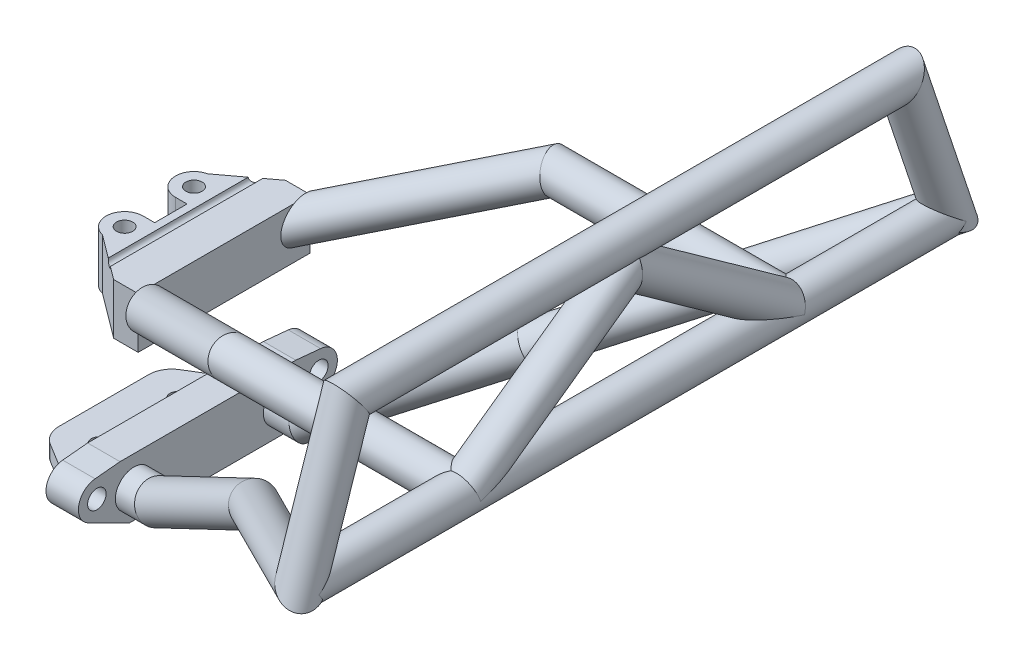
from build123d import *

# Parameters (mm, degrees)
SKETCH1_R               = 1.7
BOSS_EXTRUDE1_DEPTH     = 12.5
SKETCH2_W               = 15.5
SKETCH2_H               = 9.3
CUT_EXTRUDE1_DEPTH      = 55.465585465
BOSS_EXTRUDE2_DEPTH     = 7
CUT_EXTRUDE2_START      = -7
CUT_EXTRUDE2_DEPTH      = 15.157895
CUT_EXTRUDE3_REACH      = 36.358
SKETCH6_R               = 2
BOSS_EXTRUDE3_DEPTH     = 15
CUT_EXTRUDE4_REACH      = 39.104
SKETCH8_W               = 4.5
SKETCH8_H               = 10
SWEEP1_PROFILE_R        = 4
SWEEP4_PROFILE_R        = 4
SWEEP5_PROFILE_R        = 4
SKETCH107_W             = 7.357095587
SKETCH107_H             = 45.138164382
CUT_EXTRUDE5_DEPTH      = 10
CUT_EXTRUDE5_DEPTH_BACK = 10
SKETCH106_R             = 1.75
BOSS_EXTRUDE4_DEPTH     = 5.5
CUT_EXTRUDE6_DEPTH      = 163.309191318


with BuildPart() as part:
    # Sketch1 → Boss-Extrude1 (new body)
    with BuildSketch(Plane(origin=(0, 0, 0), x_dir=(1, 0, 0), z_dir=(0, 1, 0))):
        with BuildLine():
            Line((0, 24), (0, -24))
            Line((0, -24), (-7, -24))
            Line((-7, -24), (-7, -22))
            Line((-7, -22), (-20.11281029, -13.963116274))
            ThreePointArc((-20.11281029, -13.963116274), (-21.862570999, -12.143053785), (-22.5, -9.700110012))
            Line((-22.5, -9.700110012), (-22.5, 9.700110012))
            ThreePointArc((-22.5, 9.700110012), (-21.862570999, 12.143053785), (-20.11281029, 13.963116274))
            Line((-20.11281029, 13.963116274), (-7, 22))
            Line((-7, 22), (-7, 24))
            Line((-7, 24), (0, 24))
        make_face()
        with Locations(Location((-15, -8.5, 0), (0, 0, 270))):
            Circle(SKETCH1_R, mode=Mode.SUBTRACT)
        with Locations(Location((-15, 8.5, 0), (0, 0, 90))):
            Circle(SKETCH1_R, mode=Mode.SUBTRACT)
    extrude(amount=BOSS_EXTRUDE1_DEPTH)

    # Sketch2 → Cut-Extrude1 (cut, through all)
    with BuildSketch(Plane.XY.offset(24)):
        with Locations((-14.75, 7.85)):
            Rectangle(SKETCH2_W, SKETCH2_H)
    extrude(amount=-CUT_EXTRUDE1_DEPTH, mode=Mode.SUBTRACT)

    # Sketch4 → Boss-Extrude2 (add)
    with BuildSketch(Plane.ZY.offset(7)):
        with BuildLine():
            Line((25.797906634, 4.426831695), (24, 3.522181259))
            Line((24, 3.522181259), (24, 12.018504252))
            Line((24, 12.018504252), (24.38342286, 11.981580956))
            ThreePointArc((24.38342286, 11.981580956), (27.931680136, 8.736132671), (25.797906634, 4.426831695))
        make_face()
        with BuildLine():
            Line((-24, 3.522181259), (-24, 12.018504252))
            Line((-24, 12.018504252), (-24.38342286, 11.981580956))
            ThreePointArc((-24.38342286, 11.981580956), (-27.931680136, 8.736132671), (-25.797906634, 4.426831695))
            Line((-25.797906634, 4.426831695), (-24, 3.522181259))
        make_face()
    extrude(amount=-BOSS_EXTRUDE2_DEPTH)

    # Sketch5 → Cut-Extrude2 (cut)
    with BuildSketch(Plane.ZY.offset(7).offset(CUT_EXTRUDE2_START)):
        Polygon((24, 3.522181259), (17, 0), (24, 0), align=None)
        Polygon((24, 12.018504252), (19, 12.5), (24, 12.5), align=None)
        Polygon((-24, 12.5), (-24, 12.018504252), (-19, 12.5), align=None)
        Polygon((-24, 0), (-24, 3.522181259), (-17, 0), align=None)
    extrude(amount=CUT_EXTRUDE2_DEPTH, mode=Mode.SUBTRACT)

    # Sketch6 → Cut-Extrude3 (cut, up to next)
    with BuildSketch(Plane.ZY.offset(7), mode=Mode.PRIVATE) as cut_extrude3_sk1:
        with Locations((-24, 8)):
            Circle(SKETCH6_R)
    cut_extrude3_tool1 = extrude(cut_extrude3_sk1.sketch, amount=-CUT_EXTRUDE3_REACH, mode=Mode.PRIVATE) & part.part
    # Sketch6 → Cut-Extrude3 (cut, up to next)
    with BuildSketch(Plane.ZY.offset(7), mode=Mode.PRIVATE) as cut_extrude3_sk2:
        with Locations((24, 8)):
            Circle(SKETCH6_R)
    cut_extrude3_tool2 = extrude(cut_extrude3_sk2.sketch, amount=-CUT_EXTRUDE3_REACH, mode=Mode.PRIVATE) & part.part
    add(cut_extrude3_tool1.solids().sort_by_distance((-7, 8, -24))[0], mode=Mode.SUBTRACT)
    add(cut_extrude3_tool2.solids().sort_by_distance((-7, 8, 24))[0], mode=Mode.SUBTRACT)

    # Sketch7 → Boss-Extrude3 (add, symmetric)
    with BuildSketch(Plane.XY):
        Polygon((-11.5, 3.2), (-7, 3.2), (-7, 5.7), align=None)
    extrude(amount=BOSS_EXTRUDE3_DEPTH, both=True)

    # Cut-Extrude4: up to this face of the body (flat: up to its plane)
    cut_extrude4_end = Plane(part.part.faces().sort_by_distance((-9.25, 4.45, 0))[0])
    # Sketch8 → Cut-Extrude4 (cut, up to the picked face)
    with BuildSketch(Plane(origin=(0, 3.2, 0), x_dir=(1, 0, 0), z_dir=(0, 1, 0)), mode=Mode.PRIVATE) as cut_extrude4_sk1:
        with Locations((-9.25, 0)):
            Rectangle(SKETCH8_W, SKETCH8_H)
    cut_extrude4_tool1 = split(extrude(cut_extrude4_sk1.sketch, amount=CUT_EXTRUDE4_REACH, mode=Mode.PRIVATE), bisect_by=cut_extrude4_end, keep=Keep.BOTH, mode=Mode.PRIVATE)
    add(cut_extrude4_tool1.solids().sort_by(Axis((-9.25, 3.2, 0), (0, 1, 0)))[0], mode=Mode.SUBTRACT)

    # Sweep1: sweep along a curve in space
    with BuildLine() as sweep1_path:
        Line((0, 6, 16), (5, 6, 16))
        Line((5, 6, 16), (40, 30, 30))
        Line((40, 30, 30), (90, 60, 70))
        Line((90, 60, 70), (90, 90, 60))
        Line((90, 90, 60), (90, 90, -60))
        Line((90, 90, -60), (90, 60, -70))
        Line((40, 30, -30), (90, 60, -70))
        Line((5, 6, -16), (40, 30, -30))
        Line((0, 6, -16), (5, 6, -16))
    # Sweep1 profile (on start of the path) → Sweep1 (sweep)
    with BuildSketch(Plane(origin=(0, 6, 16), x_dir=(0, 0, 1), z_dir=(1, 0, 0))):
        Circle(SWEEP1_PROFILE_R)
    sweep(path=sweep1_path.line, transition=Transition.RIGHT)



with BuildPart() as body_2:
    # Sweep4: sweep along a curve in space
    with BuildLine() as sweep4_path:
        Line((40, 60, -35), (0, 40, -15))
        Line((90, 60, -35), (40, 60, -35))
        Line((90, 60, -35), (90, 60, 35))
        Line((90, 60, 35), (40, 60, 35))
        Line((40, 60, 35), (0, 40, 15))
    # Sweep4 profile (on start of the path) → Sweep4 (sweep)
    with BuildSketch(Plane(origin=(0, 40, 15), x_dir=(-0.4472135954999578, 0, 0.894427190999916), z_dir=(0.816496580927726, 0.40824829046386285, 0.40824829046386285))):
        Circle(SWEEP4_PROFILE_R)
    sweep(path=sweep4_path.line, transition=Transition.RIGHT)


with BuildPart() as part_1:
    add(part.part)

    add(body_2.part)  # Sweep5 merges body 2
    # Sweep5: sweep along a curve in space
    with BuildLine() as sweep5_path:
        Line((90, 60, -70), (90, 60, -35))
        Line((90, 60, -35), (90, 85, 0))
        Line((90, 85, 0), (90, 60, 35))
        Line((90, 60, 35), (90, 60, 70))
    # Sweep5 profile (on start of the path) → Sweep5 (sweep)
    with BuildSketch(Plane(origin=(90, 60, -70), x_dir=(1, 0, 0), z_dir=(0, 0, 1))):
        Circle(SWEEP5_PROFILE_R)
    sweep(path=sweep5_path.line, transition=Transition.RIGHT)

    # Sketch107 → Cut-Extrude5 (cut, two sides)
    with BuildSketch(Plane(origin=(0, 40, 0), x_dir=(1, 0, 0), z_dir=(0, 1, 0))) as cut_extrude5_sk:
        with Locations((-0.178547794, 0.105399285)):
            Rectangle(SKETCH107_W, SKETCH107_H)
    extrude(amount=CUT_EXTRUDE5_DEPTH, mode=Mode.SUBTRACT)
    extrude(cut_extrude5_sk.sketch, amount=-CUT_EXTRUDE5_DEPTH_BACK, mode=Mode.SUBTRACT)

    # Sketch106 → Boss-Extrude4 (add, symmetric)
    with BuildSketch(Plane(origin=(0, 40, 0), x_dir=(1, 0, 0), z_dir=(0, 1, 0))):
        with BuildLine():
            Line((-1.788854382, -18.577708764), (-11.388819442, -11.4))
            ThreePointArc((-11.388819442, -11.4), (-14.474921383, -7.052786405), (-10.5, -3.5))
            Line((-10.5, -3.5), (-8, -3.5))
            Line((-8, -3.5), (-8, 3.5))
            Line((-8, 3.5), (-10.5, 3.5))
            ThreePointArc((-10.5, 3.5), (-14.474921383, 7.052786405), (-11.388819442, 11.4))
            Line((-11.388819442, 11.4), (-1.788854382, 18.577708764))
            Line((-1.788854382, 18.577708764), (3.501145618, 18.577708764))
            Line((3.501145618, 18.577708764), (3.501145618, -18.577708764))
            Line((3.501145618, -18.577708764), (-1.788854382, -18.577708764))
        make_face()
        with Locations(Location((-10.5, 7.5, 0), (0, 0, 180))):
            Circle(SKETCH106_R, mode=Mode.SUBTRACT)
        with Locations(Location((-10.5, -7.5, 0), (0, 0, 180))):
            Circle(SKETCH106_R, mode=Mode.SUBTRACT)
    extrude(amount=BOSS_EXTRUDE4_DEPTH, both=True)

    # Sketch108 → Cut-Extrude6 (cut, through all)
    with BuildSketch(Plane(origin=(0, 0, -18.577708764), x_dir=(-1, 0, 0), z_dir=(0, 0, -1))):
        with BuildLine():
            Line((4.6, 45.5), (6.4, 45.5))
            ThreePointArc((6.4, 45.5), (5.5, 44.6), (4.6, 45.5))
        make_face()
    extrude(amount=-CUT_EXTRUDE6_DEPTH, mode=Mode.SUBTRACT)


solid = part_1.part
